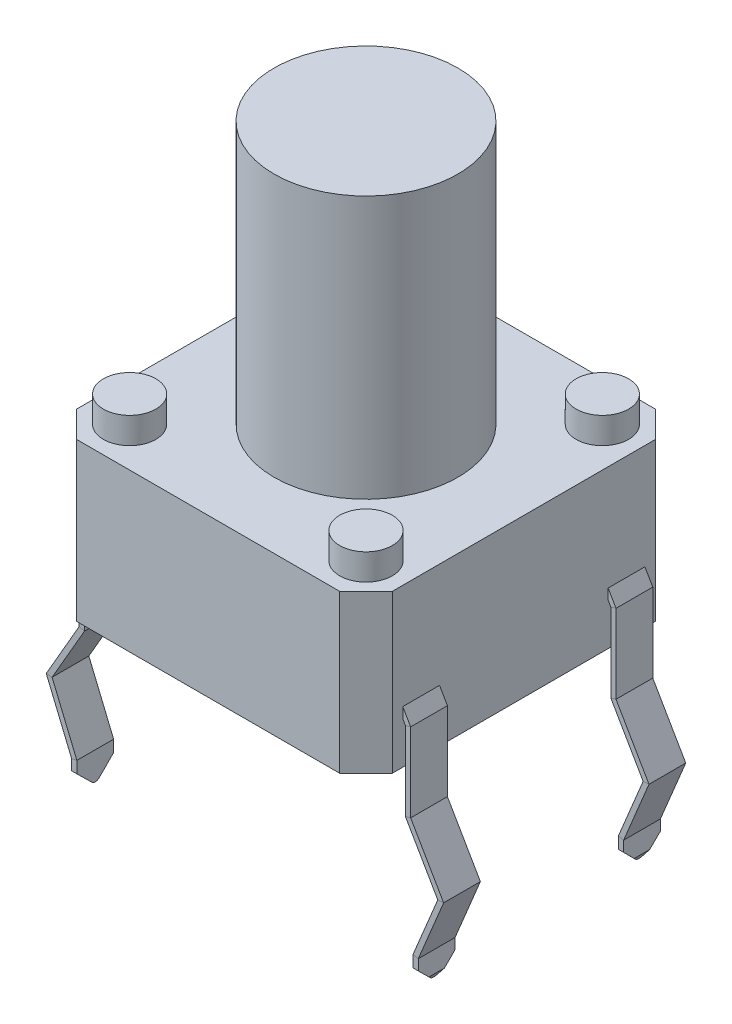
from build123d import *

# Parameters (mm, degrees)
SKETCH1_W               = 6.01
SKETCH1_H               = 6.01
BOSS_EXTRUDE1_DEPTH     = 3
CHAMFER1_SIZE           = 0.5
SKETCH3_R               = 1.75
BOSS_EXTRUDE2_DEPTH     = 5
SKETCH4_R               = 0.5
BOSS_EXTRUDE6_DEPTH     = 0.5
SKETCH5_R               = 0.5
BOSS_EXTRUDE7_DEPTH     = 0.5
SKETCH6_W               = 0.7
SKETCH6_H               = 0.2
MIRROR2_COPY_1_SKETCH_W = 0.7
MIRROR2_COPY_1_SKETCH_H = 0.2
CUT_EXTRUDE1_DEPTH      = 4.782799277


with BuildPart() as part:
    # Sketch1 → Boss-Extrude1 (new body)
    with BuildSketch(Plane(origin=(0, 0, 0), x_dir=(1, 0, 0), z_dir=(0, 1, 0))):
        Rectangle(SKETCH1_W, SKETCH1_H)
    extrude(amount=BOSS_EXTRUDE1_DEPTH)

    # Chamfer1
    chamfer1_edges = [part.edges().sort_by_distance(p)[0] for p in [
        (3.005, 1.5, 3.005),
        (-3.005, 1.5, 3.005),
        (-3.005, 1.5, -3.005),
        (3.005, 1.5, -3.005),
    ]]
    chamfer(chamfer1_edges, length=CHAMFER1_SIZE)

    # Sketch3 → Boss-Extrude2 (add)
    with BuildSketch(Plane(origin=(0, 3, 0), x_dir=(1, 0, 0), z_dir=(0, 1, 0))):
        Circle(SKETCH3_R)
    extrude(amount=BOSS_EXTRUDE2_DEPTH)

    # Sketch4 → Boss-Extrude6 (add)
    with BuildSketch(Plane(origin=(0, 3, 0), x_dir=(1, 0, 0), z_dir=(0, 1, 0))):
        with Locations((2.25, 2.25)):
            Circle(SKETCH4_R)
        with Locations((2.25, -2.25)):
            Circle(SKETCH4_R)
        with Locations((-2.25, 2.25)):
            Circle(SKETCH4_R)
    extrude(amount=BOSS_EXTRUDE6_DEPTH)

    # Sketch5 → Boss-Extrude7 (add)
    with BuildSketch(Plane(origin=(0, 3, 0), x_dir=(1, 0, 0), z_dir=(0, 1, 0))):
        with Locations((-2.25, -2.25)):
            Circle(SKETCH5_R)
    extrude(amount=BOSS_EXTRUDE7_DEPTH)

    # Sweep1: sweep along a path in Sketch7
    with BuildLine(Plane.XY) as sweep1_path:
        Line((-3.005, 0.9), (-3.105, 0.726794919))
        Line((-3.105, 0.726794919), (-3.105, -0.773205081))
        Line((-3.105, -0.773205081), (-3.72715614, -1.850811126))
        Line((-3.72715614, -1.850811126), (-3.25, -3))
        Line((-3.25, -3), (-3.25, -3.5))
    # Sketch6 → Sweep1 (sweep)
    with BuildSketch(Plane.ZY.offset(3.005)):
        with Locations((-1.955, 0.9)):
            Rectangle(SKETCH6_W, SKETCH6_H)
    sweep1 = sweep(path=sweep1_path.line, transition=Transition.RIGHT)

    # Mirror1: Sweep1 across plane
    add(sweep1.mirror(Plane.XY))

    # Mirror2: Sweep1 across plane
    add(sweep1.mirror(Plane(origin=(0, 0, 0), x_dir=(0, 0, 1), z_dir=(1, 0, 0))))

    # Mirror2 copy 1: sweep along a path in Mirror2 copy 1 path
    with BuildLine(Plane(origin=(0, 0, 0), x_dir=(-1, 0, 0), z_dir=(0, 0, -1))) as mirror2_copy_1_path:
        Line((-3.005, 0.9), (-3.105, 0.726794919))
        Line((-3.105, 0.726794919), (-3.105, -0.773205081))
        Line((-3.105, -0.773205081), (-3.72715614, -1.850811126))
        Line((-3.72715614, -1.850811126), (-3.25, -3))
        Line((-3.25, -3), (-3.25, -3.5))
    # Mirror2 copy 1 sketch → Mirror2 copy 1 (sweep)
    with BuildSketch(Plane(origin=(3.005, 0, 0), x_dir=(0, 0, -1), z_dir=(1, 0, 0))):
        with Locations((-1.955, 0.9)):
            Rectangle(MIRROR2_COPY_1_SKETCH_W, MIRROR2_COPY_1_SKETCH_H)
    sweep(path=mirror2_copy_1_path.line, transition=Transition.RIGHT)

    # Sketch8 → Cut-Extrude1 (cut, symmetric)
    with BuildSketch(Plane(origin=(0, 0, 0), x_dir=(0, 0, -1), z_dir=(1, 0, 0))):
        with BuildLine():
            Line((-2.305, -3.211682602), (-2.305, -3.58660254))
            Line((-2.305, -3.58660254), (-1.605, -3.58660254))
            Line((-1.605, -3.58660254), (-1.605, -3.211682602))
            Line((-1.605, -3.211682602), (-1.881694927, -3.48928466))
            ThreePointArc((-1.881694927, -3.48928466), (-1.952077784, -3.518688814), (-2.022718654, -3.489910032))
            Line((-2.022718654, -3.489910032), (-2.305, -3.211682602))
        make_face()
    cut_extrude1 = extrude(amount=CUT_EXTRUDE1_DEPTH, both=True, mode=Mode.SUBTRACT)

    # Mirror3: Cut-Extrude1 across plane
    add(cut_extrude1.mirror(Plane.XY), mode=Mode.SUBTRACT)


solid = part.part
